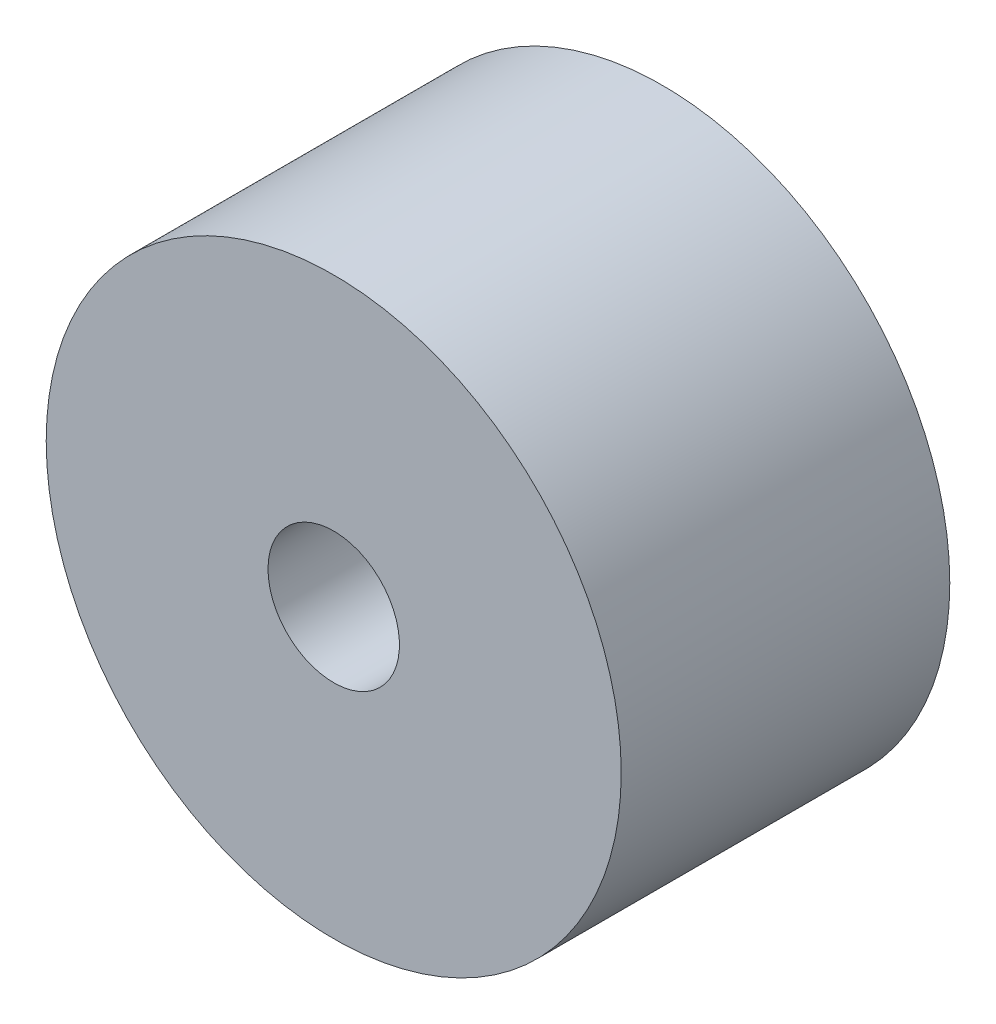
from build123d import *

# Parameters (mm, degrees)
SKETCH2_R           = 17.5
BOSS_EXTRUDE1_DEPTH = 20
SKETCH3_R           = 4
CUT_EXTRUDE1_DEPTH  = 21


with BuildPart() as part:
    # Sketch2 → Boss-Extrude1 (new body)
    with BuildSketch(Plane.XY):
        Circle(SKETCH2_R)
    extrude(amount=BOSS_EXTRUDE1_DEPTH)

    # Sketch3 → Cut-Extrude1 (cut, through all)
    with BuildSketch(Plane(origin=(0, 0, 0), x_dir=(-1, 0, 0), z_dir=(0, 0, -1))):
        Circle(SKETCH3_R)
    extrude(amount=-CUT_EXTRUDE1_DEPTH, mode=Mode.SUBTRACT)


solid = part.part
